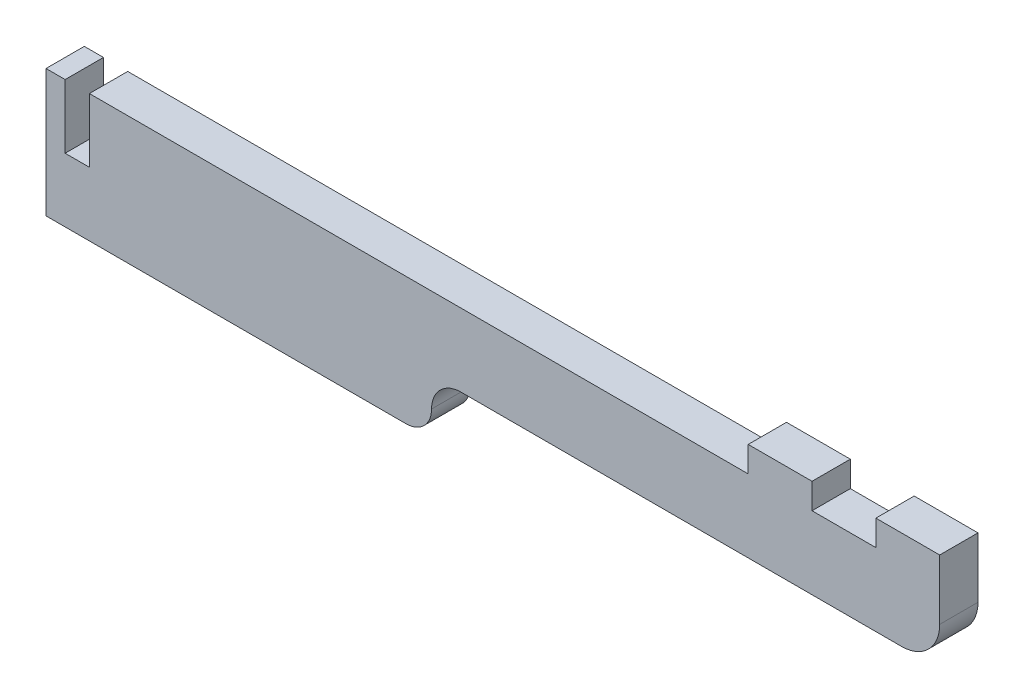
from build123d import *

# Parameters (mm, degrees)
SKIZZE1_W                       = 140
SKIZZE1_H                       = 20
AUFSATZ_LINEAR_AUSTRAGEN1_DEPTH = 6
SKIZZE2_W                       = 10
SKIZZE2_H                       = 4
AUFSATZ_LINEAR_AUSTRAGEN2_DEPTH = 6
SCHNITT_LINEAR_AUSTRAGEN1_REACH = 8
SKIZZE3_W                       = 3.8
SKIZZE3_H                       = 10
SCHNITT_LINEAR_AUSTRAGEN2_REACH = 8


with BuildPart() as part:
    # Skizze1 → Aufsatz-Linear austragen1 (new body)
    with BuildSketch(Plane.XY):
        with Locations((70, 10)):
            Rectangle(SKIZZE1_W, SKIZZE1_H)
    extrude(amount=AUFSATZ_LINEAR_AUSTRAGEN1_DEPTH)

    # Skizze2 → Aufsatz-Linear austragen2 (add)
    with BuildSketch(Plane(origin=(0, 0, 0), x_dir=(-1, 0, 0), z_dir=(0, 0, -1))):
        with Locations((-135, 22)):
            Rectangle(SKIZZE2_W, SKIZZE2_H)
        with Locations((-115, 22)):
            Rectangle(SKIZZE2_W, SKIZZE2_H)
    extrude(amount=-AUFSATZ_LINEAR_AUSTRAGEN2_DEPTH)

    # Skizze3 → Schnitt-Linear austragen1 (cut, up to next)
    with BuildSketch(Plane(origin=(0, 0, 0), x_dir=(-1, 0, 0), z_dir=(0, 0, -1)), mode=Mode.PRIVATE) as schnitt_linear_austragen1_sk1:
        with Locations((-4.9, 15)):
            Rectangle(SKIZZE3_W, SKIZZE3_H)
    schnitt_linear_austragen1_tool1 = extrude(schnitt_linear_austragen1_sk1.sketch, amount=-SCHNITT_LINEAR_AUSTRAGEN1_REACH, mode=Mode.PRIVATE) & part.part
    add(schnitt_linear_austragen1_tool1.solids().sort_by_distance((4.9, 15, 0))[0], mode=Mode.SUBTRACT)

    # Skizze4 → Schnitt-Linear austragen2 (cut, up to next)
    with BuildSketch(Plane.XY.offset(6), mode=Mode.PRIVATE) as schnitt_linear_austragen2_sk1:
        with BuildLine():
            Line((134.01576743, 8.6), (65, 8.6))
            ThreePointArc((65, 8.6), (61.747308807, 7.252691193), (60.4, 4))
            ThreePointArc((60.4, 4), (59.228427125, 1.171572875), (56.4, 0))
            Line((56.4, 0), (140, 0))
            Line((140, 0), (140, 14.58423257))
            ThreePointArc((140, 14.58423257), (138.247258861, 10.352741139), (134.01576743, 8.6))
        make_face()
    schnitt_linear_austragen2_tool1 = extrude(schnitt_linear_austragen2_sk1.sketch, amount=-SCHNITT_LINEAR_AUSTRAGEN2_REACH, mode=Mode.PRIVATE) & part.part
    add(schnitt_linear_austragen2_tool1.solids().sort_by_distance((100.680271, 4.324252, 6))[0], mode=Mode.SUBTRACT)


solid = part.part
